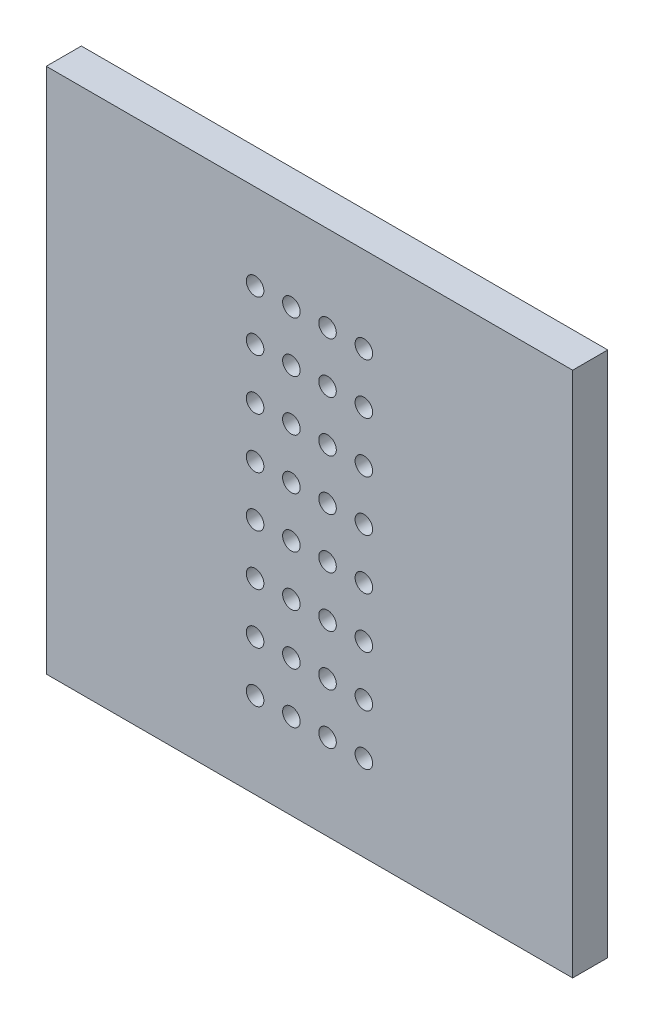
from build123d import *

# Parameters (mm, degrees)
ESQUISSE1_W            = 30
ESQUISSE1_H            = 30
BASE_PLATE_DEPTH       = 2
SKETCH_PERFORATIONS_R  = 0.5
CUT_PERFORATIONS_DEPTH = 10


with BuildPart() as part:
    # Esquisse1 → Base_Plate (new body)
    with BuildSketch(Plane.XY):
        Rectangle(ESQUISSE1_W, ESQUISSE1_H)
    extrude(amount=BASE_PLATE_DEPTH)

    # Sketch_Perforations → Cut_Perforations (cut)
    with BuildSketch(Plane.XY.offset(2)):
        with Locations((-3.1, -10.11)):
            Circle(SKETCH_PERFORATIONS_R)
        with Locations((-3.1, -7.22)):
            Circle(SKETCH_PERFORATIONS_R)
        with Locations((-3.1, -4.33)):
            Circle(SKETCH_PERFORATIONS_R)
        with Locations((-3.1, -1.44)):
            Circle(SKETCH_PERFORATIONS_R)
        with Locations((-3.1, 1.44)):
            Circle(SKETCH_PERFORATIONS_R)
        with Locations((-3.1, 4.33)):
            Circle(SKETCH_PERFORATIONS_R)
        with Locations((-3.1, 7.22)):
            Circle(SKETCH_PERFORATIONS_R)
        with Locations((-3.1, 10.11)):
            Circle(SKETCH_PERFORATIONS_R)
        with Locations((-1.03, -10.11)):
            Circle(SKETCH_PERFORATIONS_R)
        with Locations((-1.03, -7.22)):
            Circle(SKETCH_PERFORATIONS_R)
        with Locations((-1.03, -4.33)):
            Circle(SKETCH_PERFORATIONS_R)
        with Locations((-1.03, -1.44)):
            Circle(SKETCH_PERFORATIONS_R)
        with Locations((-1.03, 1.44)):
            Circle(SKETCH_PERFORATIONS_R)
        with Locations((-1.03, 4.33)):
            Circle(SKETCH_PERFORATIONS_R)
        with Locations((-1.03, 7.22)):
            Circle(SKETCH_PERFORATIONS_R)
        with Locations((-1.03, 10.11)):
            Circle(SKETCH_PERFORATIONS_R)
        with Locations((1.03, -10.11)):
            Circle(SKETCH_PERFORATIONS_R)
        with Locations((1.03, -7.22)):
            Circle(SKETCH_PERFORATIONS_R)
        with Locations((1.03, -4.33)):
            Circle(SKETCH_PERFORATIONS_R)
        with Locations((1.03, -1.44)):
            Circle(SKETCH_PERFORATIONS_R)
        with Locations((1.03, 1.44)):
            Circle(SKETCH_PERFORATIONS_R)
        with Locations((1.03, 4.33)):
            Circle(SKETCH_PERFORATIONS_R)
        with Locations((1.03, 7.22)):
            Circle(SKETCH_PERFORATIONS_R)
        with Locations((1.03, 10.11)):
            Circle(SKETCH_PERFORATIONS_R)
        with Locations((3.1, -10.11)):
            Circle(SKETCH_PERFORATIONS_R)
        with Locations((3.1, -7.22)):
            Circle(SKETCH_PERFORATIONS_R)
        with Locations((3.1, -4.33)):
            Circle(SKETCH_PERFORATIONS_R)
        with Locations((3.1, -1.44)):
            Circle(SKETCH_PERFORATIONS_R)
        with Locations((3.1, 1.44)):
            Circle(SKETCH_PERFORATIONS_R)
        with Locations((3.1, 4.33)):
            Circle(SKETCH_PERFORATIONS_R)
        with Locations((3.1, 7.22)):
            Circle(SKETCH_PERFORATIONS_R)
        with Locations((3.1, 10.11)):
            Circle(SKETCH_PERFORATIONS_R)
    extrude(amount=-CUT_PERFORATIONS_DEPTH, mode=Mode.SUBTRACT)


solid = part.part
